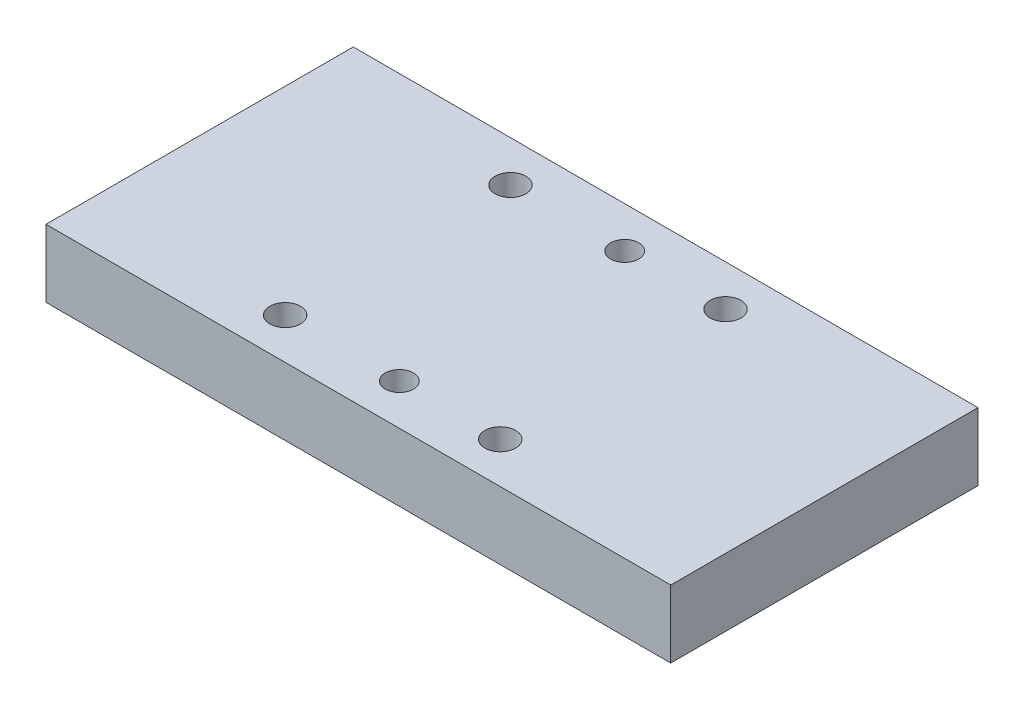
from build123d import *

# Parameters (mm, degrees)
SKETCH1_W           = 122
SKETCH1_H           = 60
SKETCH1_R           = 3
SKETCH1_R_2         = 2.75
BOSS_EXTRUDE2_DEPTH = 13.2


with BuildPart() as part:
    # Sketch1 → Boss-Extrude2 (new body)
    with BuildSketch(Plane(origin=(0, 0, 0), x_dir=(1, 0, 0), z_dir=(0, 1, 0))):
        Rectangle(SKETCH1_W, SKETCH1_H)
        with Locations((19.698113208, 22)):
            Circle(SKETCH1_R, mode=Mode.SUBTRACT)
        with Locations((-22.301886792, 22)):
            Circle(SKETCH1_R, mode=Mode.SUBTRACT)
        with Locations((-22.301886792, -22)):
            Circle(SKETCH1_R, mode=Mode.SUBTRACT)
        with Locations((19.698113208, -22)):
            Circle(SKETCH1_R, mode=Mode.SUBTRACT)
        with Locations((0, 22)):
            Circle(SKETCH1_R_2, mode=Mode.SUBTRACT)
        with Locations((0, -22)):
            Circle(SKETCH1_R_2, mode=Mode.SUBTRACT)
    extrude(amount=BOSS_EXTRUDE2_DEPTH)


solid = part.part
